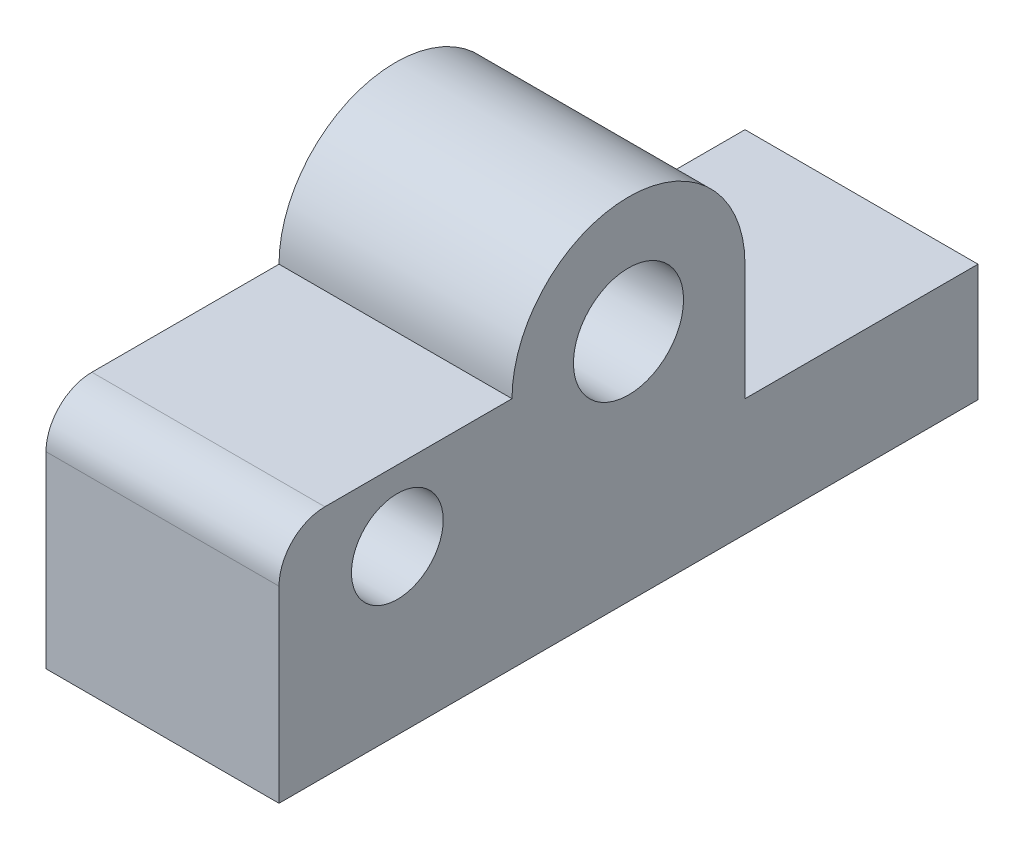
from build123d import *

# Parameters (mm, degrees)
BOSS_EXTRUDE1_DEPTH = 25.4
SKETCH2_R           = 6
SKETCH2_R_2         = 5
CUT_EXTRUDE1_DEPTH  = 26.4
FILLET1_R           = 5


with BuildPart() as part:
    # Sketch1 → Boss-Extrude1 (new body)
    with BuildSketch(Plane(origin=(0, 0, 0), x_dir=(0, 0, -1), z_dir=(1, 0, 0))):
        with BuildLine():
            Line((12.7, 0), (12.7, -12.7))
            Line((12.7, -12.7), (38.1, -12.7))
            Line((38.1, -12.7), (38.1, -25.5))
            Line((38.1, -25.5), (-38.1, -25.5))
            Line((-38.1, -25.5), (-38.1, -12.7))
            Line((-38.1, -12.7), (-38.1, 0))
            Line((-38.1, 0), (-12.7, 0))
            ThreePointArc((-12.7, 0), (0, 12.7), (12.7, 0))
        make_face()
    extrude(amount=BOSS_EXTRUDE1_DEPTH)

    # Sketch2 → Cut-Extrude1 (cut, through all)
    with BuildSketch(Plane(origin=(25.4, 0, 0), x_dir=(0, 0, -1), z_dir=(1, 0, 0))):
        Circle(SKETCH2_R)
        with Locations((-25.2, -7.7)):
            Circle(SKETCH2_R_2)
    extrude(amount=-CUT_EXTRUDE1_DEPTH, mode=Mode.SUBTRACT)

    # Fillet1
    fillet1_edges = [part.edges().sort_by_distance(p)[0] for p in [
        (12.7, 0, 38.1),
    ]]
    fillet(fillet1_edges, radius=FILLET1_R)


solid = part.part
